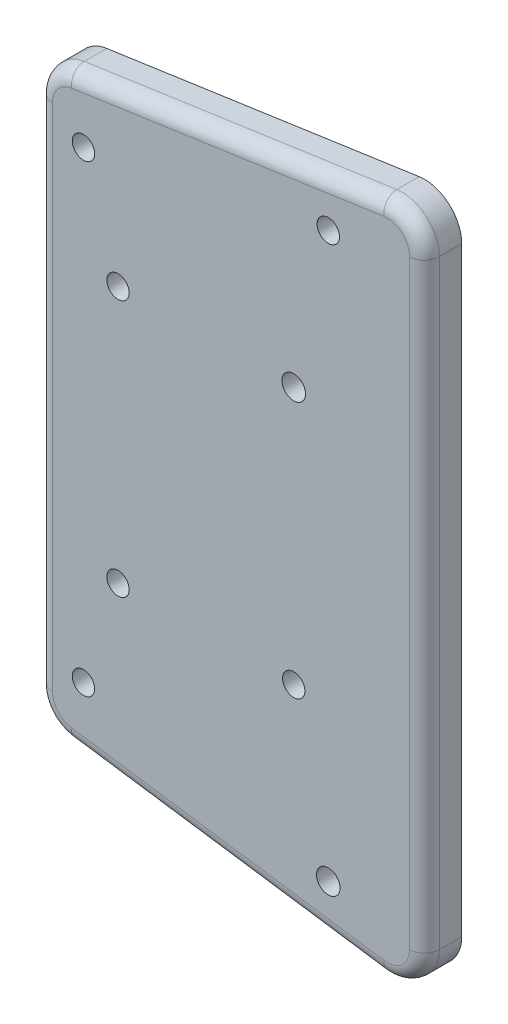
from build123d import *

# Parameters (mm, degrees)
ESQUISSE1_R        = 1.578798566
ESQUISSE1_R_2      = 1.5
ESQUISSE1_R_3      = 1.58210763
BOSS_EXTRU_1_DEPTH = 5
CONG_1_R           = 2


with BuildPart() as part:
    # Esquisse1 → Boss.-Extru.1 (new body)
    with BuildSketch(Plane.XY):
        with BuildLine():
            Line((20.236568094, -45.190021555), (-21.667832927, -39.130000484))
            ThreePointArc((-21.667832927, -39.130000484), (-24.732290594, -37.454232491), (-25.952200511, -34.181478458))
            Line((-25.952200511, -34.181478458), (-25.952200511, 34.181478458))
            ThreePointArc((-25.952200511, 34.181478458), (-24.732290594, 37.454232491), (-21.667832927, 39.130000484))
            Line((-21.667832927, 39.130000484), (20.236568094, 45.190021555))
            ThreePointArc((20.236568094, 45.190021555), (24.224954543, 44.021589613), (25.952200511, 40.241499529))
            Line((25.952200511, 40.241499529), (25.952200511, -40.241499529))
            ThreePointArc((25.952200511, -40.241499529), (24.224954543, -44.021589613), (20.236568094, -45.190021555))
        make_face()
        with Locations((13.054361823, -37.76712052)):
            Circle(ESQUISSE1_R, mode=Mode.SUBTRACT)
        with Locations((-19.786707419, -31.079856582)):
            Circle(ESQUISSE1_R_2, mode=Mode.SUBTRACT)
        with Locations((8.417830834, -17.231443917)):
            Circle(ESQUISSE1_R_2, mode=Mode.SUBTRACT)
        with Locations((-15.15017643, -17.231443917)):
            Circle(ESQUISSE1_R_2, mode=Mode.SUBTRACT)
        with Locations((8.417830834, 17.313551547)):
            Circle(ESQUISSE1_R_3, mode=Mode.SUBTRACT)
        with Locations((-15.15017643, 17.231443917)):
            Circle(ESQUISSE1_R_2, mode=Mode.SUBTRACT)
        with Locations((-19.786707419, 31.079856582)):
            Circle(ESQUISSE1_R_2, mode=Mode.SUBTRACT)
        with Locations((13.054361823, 37.845919086)):
            Circle(ESQUISSE1_R_2, mode=Mode.SUBTRACT)
    extrude(amount=BOSS_EXTRU_1_DEPTH)

    # Congé1
    cong_1_edges = [part.edges().sort_by_distance(p)[0] for p in [
        (-24.732290594, 37.454232491, 5),
        (-25.952200511, 0, 5),
        (-24.732290594, -37.454232491, 5),
        (-0.715632416, -42.16001102, 5),
        (24.224954543, -44.021589613, 5),
        (25.952200511, 0, 5),
        (24.224954543, 44.021589613, 5),
        (-0.715632416, 42.16001102, 5),
    ]]
    fillet(cong_1_edges, radius=CONG_1_R)


solid = part.part
